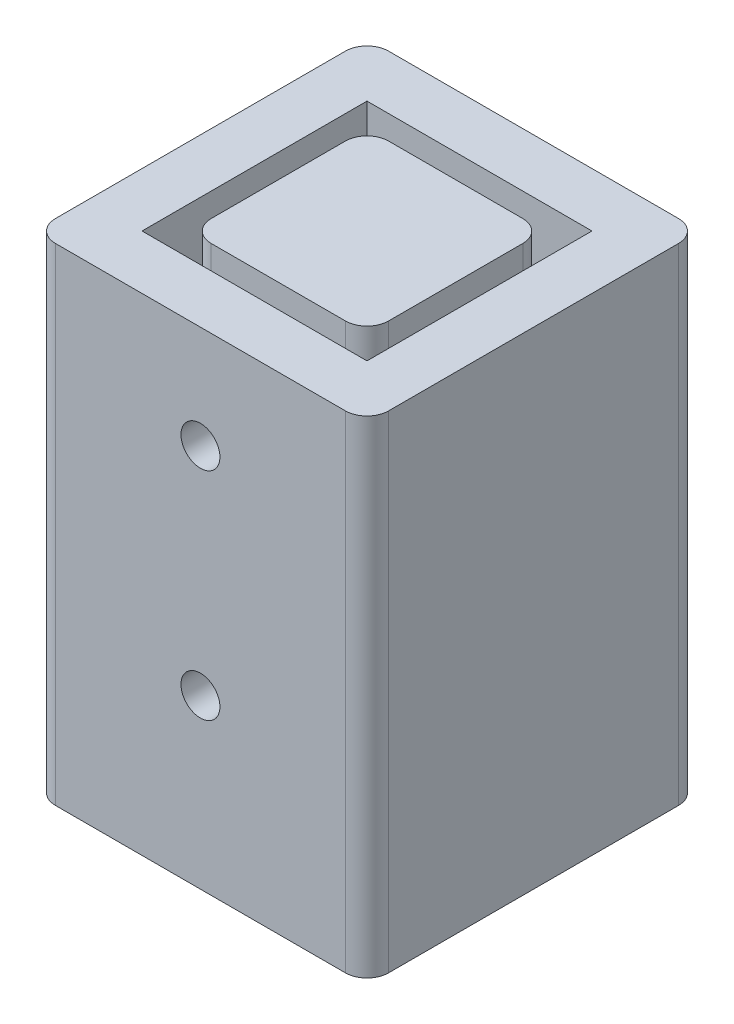
from build123d import *

# Parameters (mm, degrees)
SKETCH1_W             = 39.116
SKETCH1_H             = 39.116
SKETCH1_W_2           = 26.416
SKETCH1_H_2           = 26.416
BOSS_EXTRUDE1_DEPTH   = 50.8
SKETCH1_W_3           = 20.828
SKETCH1_H_3           = 20.828
BOSS_EXTRUDE1_2_DEPTH = 50.8
SKETCH2_R             = 2.286
CUT_EXTRUDE1_DEPTH    = 68.031461419
SKETCH1_2_W           = 39.116
SKETCH1_2_H           = 39.116
BOSS_EXTRUDE2_DEPTH   = 6.35
FILLET1_R             = 2.54


with BuildPart() as part:
    # Sketch1 → Boss-Extrude1 (new body)
    with BuildSketch(Plane(origin=(0, 0, 0), x_dir=(1, 0, 0), z_dir=(0, 1, 0))):
        Rectangle(SKETCH1_W, SKETCH1_H)
        Rectangle(SKETCH1_W_2, SKETCH1_H_2, mode=Mode.SUBTRACT)
    extrude(amount=BOSS_EXTRUDE1_DEPTH)


with BuildPart() as body_2:
    # Sketch1 → Boss-Extrude1 2 (new body)
    with BuildSketch(Plane(origin=(0, 0, 0), x_dir=(1, 0, 0), z_dir=(0, 1, 0))):
        Rectangle(SKETCH1_W_3, SKETCH1_H_3)
    extrude(amount=BOSS_EXTRUDE1_2_DEPTH)


with BuildPart() as cut_extrude1_tool:
    # Sketch2 → Cut-Extrude1 (new, through all)
    with BuildSketch(Plane.XY.offset(19.558)):
        with Locations((0, 13.335)):
            Circle(SKETCH2_R)
        with Locations((0, 38.735)):
            Circle(SKETCH2_R)
    extrude(amount=-CUT_EXTRUDE1_DEPTH)


with BuildPart() as part_1:
    add(part.part)

    # Cut-Extrude1: cut by cut_extrude1_tool
    add(cut_extrude1_tool.part, mode=Mode.SUBTRACT)



with BuildPart() as body_2_1:
    add(body_2.part)

    # Cut-Extrude1: cut by cut_extrude1_tool
    add(cut_extrude1_tool.part, mode=Mode.SUBTRACT)


with BuildPart() as part_2:
    add(part_1.part)

    add(body_2_1.part)  # Boss-Extrude2 merges body 2
    # Sketch1_2 → Boss-Extrude2 (add)
    with BuildSketch(Plane(origin=(0, 0, 0), x_dir=(1, 0, 0), z_dir=(0, 1, 0))):
        Rectangle(SKETCH1_2_W, SKETCH1_2_H)
    extrude(amount=-BOSS_EXTRUDE2_DEPTH)

    # Fillet1
    fillet1_edges = [part_2.edges().sort_by_distance(p)[0] for p in [
        (19.558, 22.225, -19.558),
        (-19.558, 22.225, -19.558),
        (19.558, 22.225, 19.558),
        (-19.558, 22.225, 19.558),
        (10.414, 25.4, -10.414),
        (-10.414, 25.4, 10.414),
        (10.414, 25.4, 10.414),
        (-10.414, 25.4, -10.414),
    ]]
    fillet(fillet1_edges, radius=FILLET1_R)


solid = part_2.part
